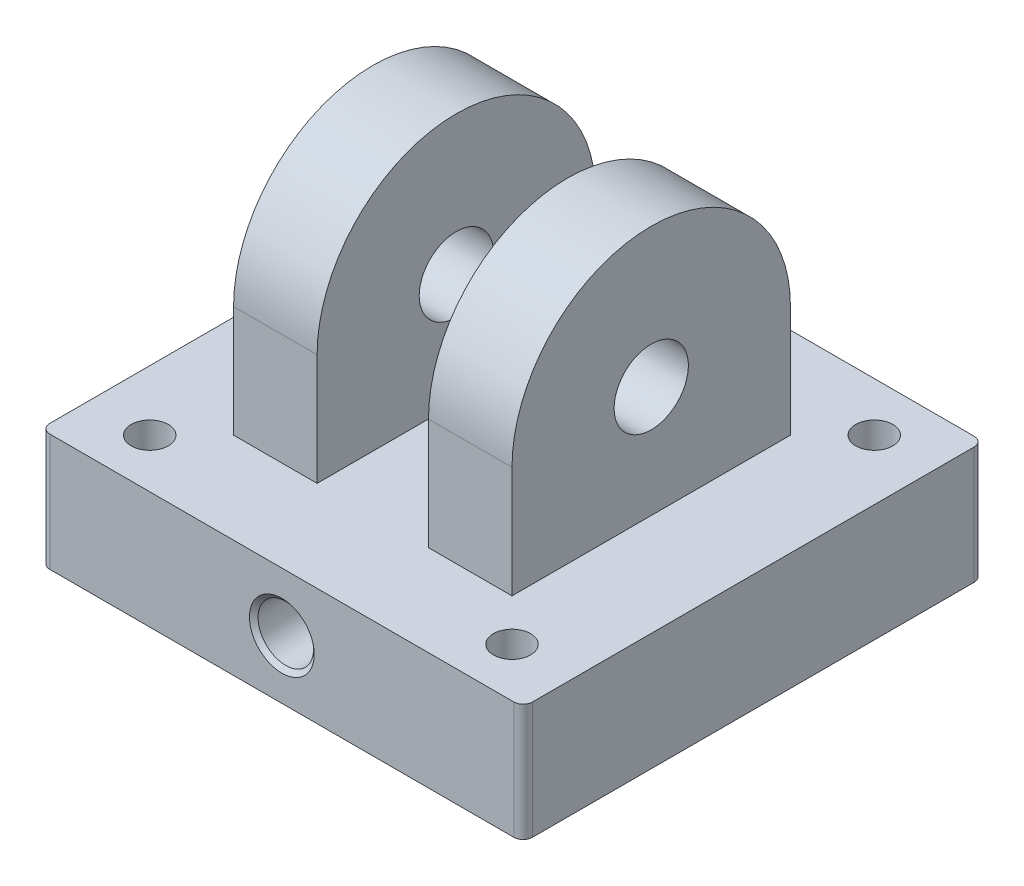
from build123d import *

# Parameters (mm, degrees)
SKETCH1_W                              = 165.1
SKETCH1_H                              = 157.469327732
BOSS_EXTRUDE1_DEPTH                    = 38.1
BOSS_EXTRUDE1_DEPTH_BACK               = 2
SKETCH2_W                              = 95.25
SKETCH2_H                              = 95.25
BOSS_EXTRUDE2_DEPTH                    = 38.1
BOSS_EXTRUDE3_START                    = -95.25
BOSS_EXTRUDE3_DEPTH                    = 95.25
SKETCH4_R                              = 12.7
CUT_EXTRUDE1_DEPTH                     = 131.175
SKETCH5_W                              = 38.1
SKETCH5_H                              = 85.725
CUT_EXTRUDE3_DEPTH                     = 127.359663866
FILLET1_R                              = 3.175
SKETCH6_R                              = 26
CUT_EXTRUDE4_DEPTH                     = 36.83
SKETCH9_R                              = 76.2
SKETCH9_R_2                            = 69.85
CUT_EXTRUDE5_DEPTH                     = 8
F_1_2_14_NPSM_TAPPED_HOLE1_D           = 18.9738
F_1_2_14_NPSM_TAPPED_HOLE1_DEPTH       = 63.5
F_1_2_14_NPSM_TAPPED_HOLE1_CSINK_D     = 22.1742
F_1_2_14_NPSM_TAPPED_HOLE1_CSINK_ANGLE = 100
F_1_2_14_NPSM_TAPPED_HOLE1_TIP         = 5.700304607
SKETCH16_R                             = 6.35
CUT_EXTRUDE6_DEPTH                     = 25
SKETCH17_R                             = 6.35
CUT_EXTRUDE7_DEPTH                     = 126.825


with BuildPart() as part:
    # Sketch1 → Boss-Extrude1 (new body, two sides)
    with BuildSketch(Plane(origin=(0, 0, 0), x_dir=(1, 0, 0), z_dir=(0, 1, 0))) as boss_extrude1_sk:
        Rectangle(SKETCH1_W, SKETCH1_H)
    extrude(amount=BOSS_EXTRUDE1_DEPTH)
    extrude(boss_extrude1_sk.sketch, amount=-BOSS_EXTRUDE1_DEPTH_BACK)

    # Sketch2 → Boss-Extrude2 (add)
    with BuildSketch(Plane(origin=(0, 38.1, 0), x_dir=(1, 0, 0), z_dir=(0, 1, 0))):
        Rectangle(SKETCH2_W, SKETCH2_H)
    extrude(amount=BOSS_EXTRUDE2_DEPTH)

    # Sketch3 → Boss-Extrude3 (add)
    with BuildSketch(Plane.ZY.offset(47.625).offset(BOSS_EXTRUDE3_START)):
        with BuildLine():
            Line((-47.625, 76.2), (47.625, 76.2))
            ThreePointArc((47.625, 76.2), (0, 123.825), (-47.625, 76.2))
        make_face()
    extrude(amount=BOSS_EXTRUDE3_DEPTH)

    # Sketch4 → Cut-Extrude1 (cut, through all)
    with BuildSketch(Plane.ZY.offset(47.625)):
        with Locations((0, 76.2)):
            Circle(SKETCH4_R)
    extrude(amount=-CUT_EXTRUDE1_DEPTH, mode=Mode.SUBTRACT)

    # Sketch5 → Cut-Extrude3 (cut, through all)
    with BuildSketch(Plane.XY.offset(47.625)):
        with Locations((0, 80.9625)):
            Rectangle(SKETCH5_W, SKETCH5_H)
    extrude(amount=-CUT_EXTRUDE3_DEPTH, mode=Mode.SUBTRACT)

    # Fillet1
    fillet1_edges = [part.edges().sort_by_distance(p)[0] for p in [
        (82.55, 18.05, 78.734663866),
        (-82.55, 18.05, 78.734663866),
        (-82.55, 18.05, -78.734663866),
        (82.55, 18.05, -78.734663866),
    ]]
    fillet(fillet1_edges, radius=FILLET1_R)

    # Sketch6 → Cut-Extrude4 (cut)
    with BuildSketch(Plane.XZ.offset(2)):
        Circle(SKETCH6_R)
    extrude(amount=-CUT_EXTRUDE4_DEPTH, mode=Mode.SUBTRACT)

    # Sketch9 → Cut-Extrude5 (cut)
    with BuildSketch(Plane.XZ.offset(2)):
        Circle(SKETCH9_R)
        Circle(SKETCH9_R_2, mode=Mode.SUBTRACT)
    extrude(amount=-CUT_EXTRUDE5_DEPTH, mode=Mode.SUBTRACT)

    # 1/2-14 NPSM Tapped Hole1
    with Locations(Plane.XY.offset(78.734663866)):
        with Locations((0, 18.05)):
            CounterSinkHole(F_1_2_14_NPSM_TAPPED_HOLE1_D / 2, F_1_2_14_NPSM_TAPPED_HOLE1_CSINK_D / 2, depth=F_1_2_14_NPSM_TAPPED_HOLE1_DEPTH, counter_sink_angle=F_1_2_14_NPSM_TAPPED_HOLE1_CSINK_ANGLE)
            with Locations((0, 0, -(F_1_2_14_NPSM_TAPPED_HOLE1_DEPTH + F_1_2_14_NPSM_TAPPED_HOLE1_TIP / 2))):  # 118° drill point
                Cone(0, F_1_2_14_NPSM_TAPPED_HOLE1_D / 2, F_1_2_14_NPSM_TAPPED_HOLE1_TIP, mode=Mode.SUBTRACT)

    # Sketch16 → Cut-Extrude6 (cut)
    with BuildSketch(Plane.XZ.offset(2)):
        with Locations((0, 46.734663866)):
            Circle(SKETCH16_R)
    extrude(amount=-CUT_EXTRUDE6_DEPTH, mode=Mode.SUBTRACT)

    # Sketch17 → Cut-Extrude7 (cut, through all)
    with BuildSketch(Plane.XZ.offset(2)):
        with Locations((-61.963767235, 61.963767235)):
            Circle(SKETCH17_R)
        with Locations((61.963767235, 61.963767235)):
            Circle(SKETCH17_R)
        with Locations((61.963767235, -61.963767235)):
            Circle(SKETCH17_R)
        with Locations((-61.963767235, -61.963767235)):
            Circle(SKETCH17_R)
    extrude(amount=-CUT_EXTRUDE7_DEPTH, mode=Mode.SUBTRACT)


solid = part.part
